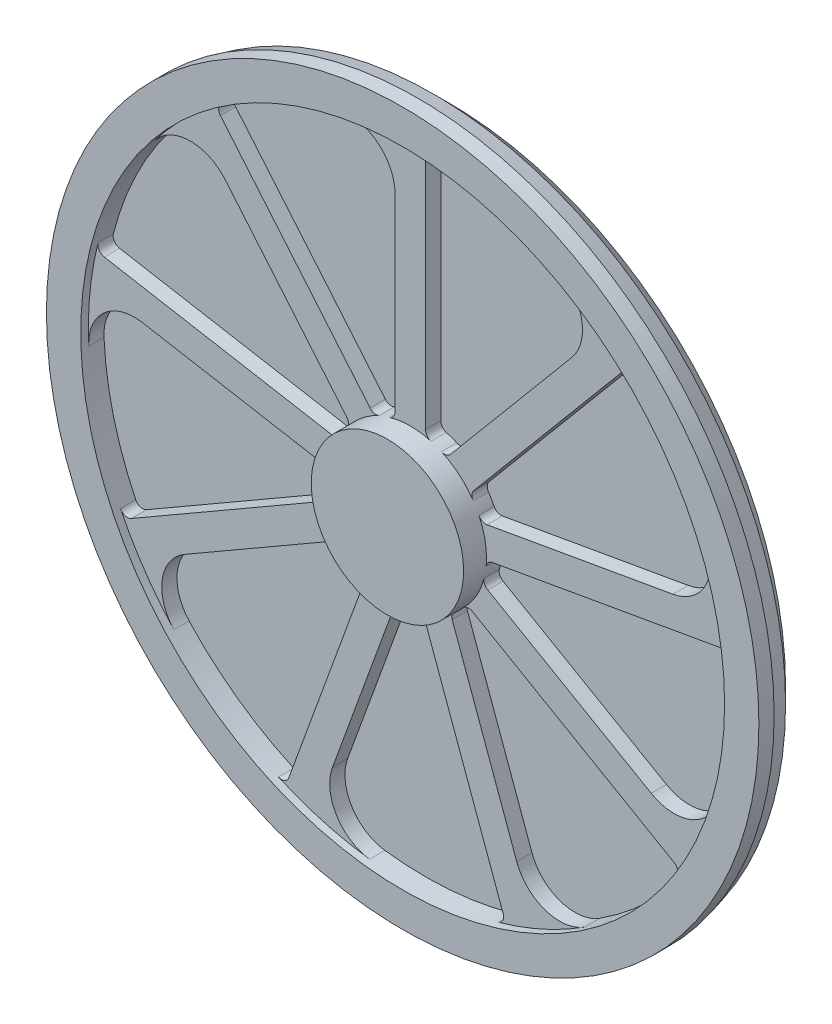
from build123d import *

# Parameters (mm, degrees)
BOSS_EXTRUDE1_DEPTH = 20


with BuildPart() as part:
    # Sketch1 → Revolve1 (revolve)
    with BuildSketch(Plane(origin=(0, 0, 0), x_dir=(0, 0, -1), z_dir=(1, 0, 0))):
        Polygon((0, 0), (80, 0), (80, 442.5), (60.490381057, 462.009618943), (40, 467.5), (20, 467.5), (20, 422.5), (50, 422.5), (50, 100), (0, 100), align=None)
    revolve(axis=Axis((0, 0, 0), (0, 0, -1)))

    # Sketch2 → Boss-Extrude1 (add)
    with BuildSketch(Plane.XY.offset(-50)):
        with BuildLine():
            Line((20, 105.830052443), (20, 411.407644557))
            ThreePointArc((20, 411.407644557), (23.19091516, 418.73132967), (30.727272727, 421.381163213))
            ThreePointArc((30.727272727, 421.381163213), (-31.600916525, 421.316546168), (-93.24137931, 412.08287417))
            ThreePointArc((-93.24137931, 412.08287417), (-42.546580654, 400.436970696), (-20, 353.562229318))
            Line((-20, 353.562229318), (-20, 105.830052443))
            ThreePointArc((-20, 105.830052443), (-22.022759648, 99.799825551), (-27.272727273, 96.209138584))
            ThreePointArc((-27.272727273, 96.209138584), (0, 100), (27.272727273, 96.209138584))
            ThreePointArc((27.272727273, 96.209138584), (22.022759648, 99.799825551), (20, 105.830052443))
        make_face()
        with BuildLine():
            ThreePointArc((294.397047194, 303.045588326), (246.609349131, 343.059876583), (193.454725191, 375.608199193))
            ThreePointArc((193.454725191, 375.608199193), (224.80335154, 334.1009311), (211.944531396, 283.700133259))
            Line((211.944531396, 283.700133259), (52.70535758, 93.926275782))
            ThreePointArc((52.70535758, 93.926275782), (47.279678663, 90.60705882), (40.949921045, 91.231047163))
            ThreePointArc((40.949921045, 91.231047163), (64.278760969, 76.604444312), (82.734163396, 56.169904816))
            ThreePointArc((82.734163396, 56.169904816), (81.020503963, 62.295144755), (83.347135305, 68.214771395))
            Line((83.347135305, 68.214771395), (279.768625314, 302.300787776))
            ThreePointArc((279.768625314, 302.300787776), (286.920582188, 305.859975332), (294.397047194, 303.045588326))
        make_face()
        with BuildLine():
            ThreePointArc((-249.126847589, 328.012292163), (-251.390038811, 335.673641176), (-247.320134144, 342.547808703))
            ThreePointArc((-247.320134144, 342.547808703), (-295.024762134, 302.434521389), (-336.30880617, 255.739392532))
            ThreePointArc((-336.30880617, 255.739392532), (-289.988494908, 279.404101342), (-242.586309121, 257.988628872))
            Line((-242.586309121, 257.988628872), (-83.347135305, 68.214771395))
            ThreePointArc((-83.347135305, 68.214771395), (-81.020503963, 62.295144755), (-82.734163396, 56.169904816))
            ThreePointArc((-82.734163396, 56.169904816), (-64.278760969, 76.604444312), (-40.949921045, 91.231047163))
            ThreePointArc((-40.949921045, 91.231047163), (-47.279678663, 90.60705882), (-52.70535758, 93.926275782))
            Line((-52.70535758, 93.926275782), (-249.126847589, 328.012292163))
        make_face()
        with BuildLine():
            ThreePointArc((420.315171419, 42.911614684), (409.428359571, 104.28167806), (389.631213766, 163.382273394))
            ThreePointArc((389.631213766, 163.382273394), (386.965297138, 111.435352724), (344.717861051, 81.091591873))
            Line((344.717861051, 81.091591873), (100.749292594, 38.073350809))
            ThreePointArc((100.749292594, 38.073350809), (94.459429872, 39.018242282), (90.011646197, 43.564934854))
            ThreePointArc((90.011646197, 43.564934854), (98.480775301, 17.364817767), (99.483364979, -10.151851674))
            ThreePointArc((99.483364979, -10.151851674), (102.107854032, -4.358126605), (107.6952197, -1.318959311))
            Line((107.6952197, -1.318959311), (408.630401562, 51.744032695))
            ThreePointArc((408.630401562, 51.744032695), (416.396920044, 49.873339281), (420.315171419, 42.911614684))
        make_face()
        with BuildLine():
            ThreePointArc((-401.684474455, 91.136342816), (-408.342799732, 95.550525378), (-409.643701592, 103.432527506))
            ThreePointArc((-409.643701592, 103.432527506), (-420.403242706, 42.040022866), (-422.013604967, -20.267393099))
            ThreePointArc((-422.013604967, -20.267393099), (-401.741569531, 27.634947739), (-351.663788158, 41.699281753))
            Line((-351.663788158, 41.699281753), (-107.6952197, -1.318959311))
            ThreePointArc((-107.6952197, -1.318959311), (-102.107854032, -4.358126605), (-99.483364979, -10.151851674))
            ThreePointArc((-99.483364979, -10.151851674), (-98.480775301, 17.364817767), (-90.011646197, 43.564934854))
            ThreePointArc((-90.011646197, 43.564934854), (-94.459429872, 39.018242282), (-100.749292594, 38.073350809))
            Line((-100.749292594, 38.073350809), (-401.684474455, 91.136342816))
        make_face()
        with BuildLine():
            ThreePointArc((349.563155655, -237.301180377), (380.671290279, -183.29107659), (403.494927151, -125.292033918))
            ThreePointArc((403.494927151, -125.292033918), (368.061879564, -163.372065657), (316.193872408, -159.460606583))
            Line((316.193872408, -159.460606583), (101.651513899, -35.594518146))
            ThreePointArc((101.651513899, -35.594518146), (97.440564044, -30.827643459), (96.955921726, -24.485694643))
            ThreePointArc((96.955921726, -24.485694643), (86.602540378, -50), (69.683194454, -71.723443941))
            ThreePointArc((69.683194454, -71.723443941), (75.417804397, -68.972182092), (81.651513899, -70.235534297))
            Line((81.651513899, -70.235534297), (346.289471498, -223.024330354))
            ThreePointArc((346.289471498, -223.024330354), (351.036511275, -229.4495865), (349.563155655, -237.301180377))
        make_face()
        with BuildLine():
            ThreePointArc((-366.289471498, -188.383314203), (-374.227426435, -189.28174317), (-380.290428382, -184.079982836))
            ThreePointArc((-380.290428382, -184.079982836), (-349.070373753, -238.025469578), (-310.253547841, -286.790840252))
            ThreePointArc((-310.253547841, -286.790840252), (-325.51529891, -237.064905039), (-296.193872408, -194.101622734))
            Line((-296.193872408, -194.101622734), (-81.651513899, -70.235534297))
            ThreePointArc((-81.651513899, -70.235534297), (-75.417804397, -68.972182092), (-69.683194454, -71.723443941))
            ThreePointArc((-69.683194454, -71.723443941), (-86.602540378, -50), (-96.955921726, -24.485694643))
            ThreePointArc((-96.955921726, -24.485694643), (-97.440564044, -30.827643459), (-101.651513899, -35.594518146))
            Line((-101.651513899, -35.594518146), (-366.289471498, -188.383314203))
        make_face()
        with BuildLine():
            ThreePointArc((115.246654398, -406.478115832), (173.793893575, -385.09989945), (228.558879776, -355.340806094))
            ThreePointArc((228.558879776, -355.340806094), (176.938217991, -361.73587884), (139.719256761, -325.399415012))
            Line((139.719256761, -325.399415012), (54.98986212, -92.607316471))
            ThreePointArc((54.98986212, -92.607316471), (54.828175369, -86.248932215), (58.533443935, -81.079195489))
            ThreePointArc((58.533443935, -81.079195489), (34.202014333, -93.969262079), (7.277482801, -99.73483967))
            ThreePointArc((7.277482801, -99.73483967), (13.438925908, -101.313387037), (17.402157289, -106.288122204))
            Line((17.402157289, -106.288122204), (121.915849141, -393.437130592))
            ThreePointArc((121.915849141, -393.437130592), (121.422217544, -401.41050071), (115.246654398, -406.478115832))
        make_face()
        with BuildLine():
            ThreePointArc((-159.503553972, -379.756324859), (-165.006881234, -385.546980456), (-172.995037276, -385.459423387))
            ThreePointArc((-172.995037276, -385.459423387), (-114.403597437, -406.716199448), (-53.322407596, -419.121665926))
            ThreePointArc((-53.322407596, -419.121665926), (-96.97680223, -390.839454066), (-102.13155193, -339.080220745))
            Line((-102.13155193, -339.080220745), (-17.402157289, -106.288122204))
            ThreePointArc((-17.402157289, -106.288122204), (-13.438925908, -101.313387037), (-7.277482801, -99.73483967))
            ThreePointArc((-7.277482801, -99.73483967), (-34.202014333, -93.969262079), (-58.533443935, -81.079195489))
            ThreePointArc((-58.533443935, -81.079195489), (-54.828175369, -86.248932215), (-54.98986212, -92.607316471))
            Line((-54.98986212, -92.607316471), (-159.503553972, -379.756324859))
        make_face()
    extrude(amount=BOSS_EXTRUDE1_DEPTH)


solid = part.part
